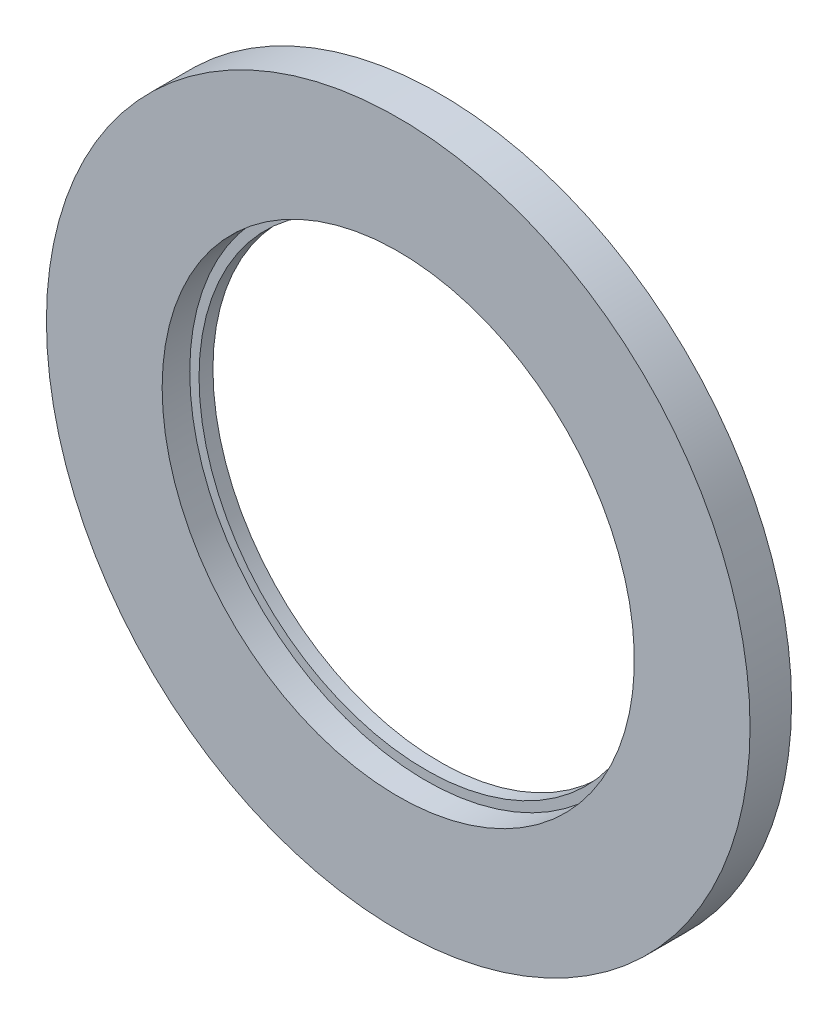
from build123d import *


with BuildPart() as part:
    # Sketch1 → Revolve1 (revolve)
    with BuildSketch(Plane.XZ):
        Polygon((48.9, 0), (75.85, 0), (75.85, 8.951), (50.9, 8.951), (50.9, 3), (48.9, 3), align=None)
    revolve(axis=Axis((0, 0, 10), (0, 0, -1)))


solid = part.part
